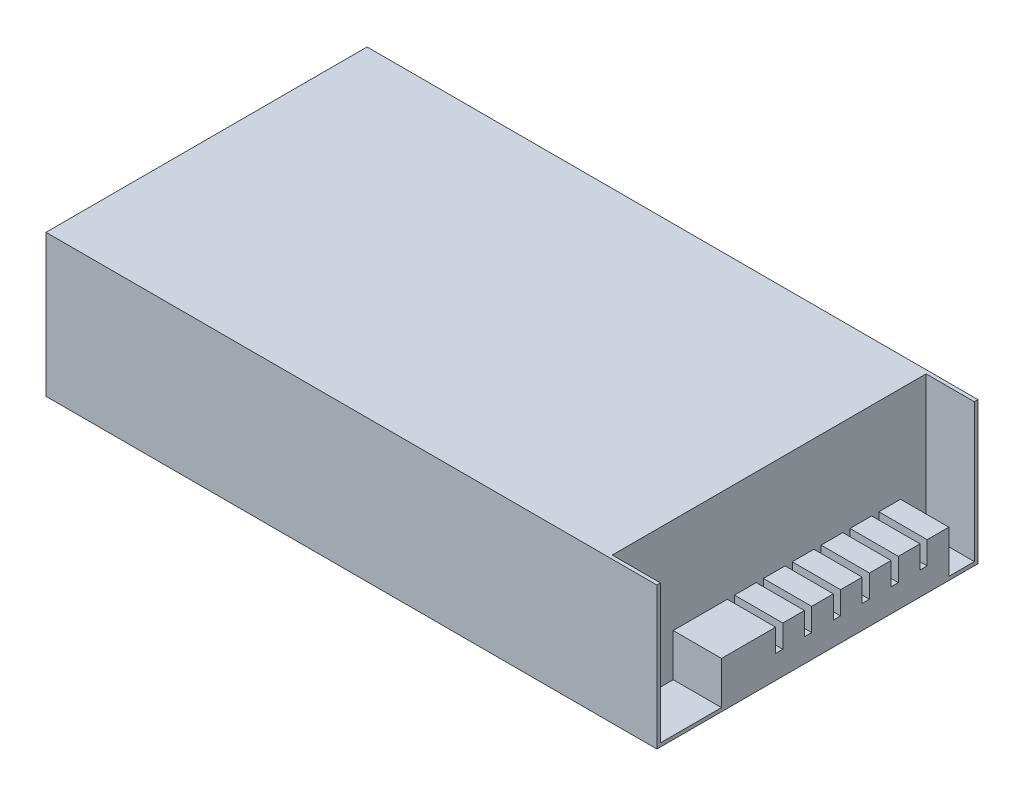
from build123d import *

# Parameters (mm, degrees)
SKETCH1_W           = 215
SKETCH1_H           = 113
BOSS_EXTRUDE1_DEPTH = 50
SKETCH2_W           = 110.46
SKETCH2_H           = 48.73
CUT_EXTRUDE1_DEPTH  = 17
SKETCH4_W           = 17
SKETCH4_H           = 80
BOSS_EXTRUDE2_DEPTH = 15
SKETCH6_R           = 1.27
CUT_EXTRUDE4_DEPTH  = 10.16
SKETCH7_W           = 17
SKETCH7_H           = 2.54
CUT_EXTRUDE5_DEPTH  = 8


with BuildPart() as part:
    # Sketch1 → Boss-Extrude1 (new body)
    with BuildSketch(Plane(origin=(0, 0, 0), x_dir=(1, 0, 0), z_dir=(0, 1, 0))):
        with Locations((107.5, 56.5)):
            Rectangle(SKETCH1_W, SKETCH1_H)
    extrude(amount=BOSS_EXTRUDE1_DEPTH)

    # Sketch2 → Cut-Extrude1 (cut)
    with BuildSketch(Plane(origin=(215, 0, 0), x_dir=(0, 0, -1), z_dir=(1, 0, 0))):
        with Locations((56.5, 25.635)):
            Rectangle(SKETCH2_W, SKETCH2_H)
    extrude(amount=-CUT_EXTRUDE1_DEPTH, mode=Mode.SUBTRACT)

    # Sketch4 → Boss-Extrude2 (add)
    with BuildSketch(Plane(origin=(0, 1.27, 0), x_dir=(1, 0, 0), z_dir=(0, 1, 0))):
        with Locations((206.5, 62.73)):
            Rectangle(SKETCH4_W, SKETCH4_H)
    extrude(amount=BOSS_EXTRUDE2_DEPTH)

    # Sketch6 → Cut-Extrude4 (cut)
    with BuildSketch(Plane.XZ):
        with Locations((113.146, -65.278)):
            Circle(SKETCH6_R)
        with Locations((190.87, -65.278)):
            Circle(SKETCH6_R)
    extrude(amount=-CUT_EXTRUDE4_DEPTH, mode=Mode.SUBTRACT)

    # Sketch7 → Cut-Extrude5 (cut)
    with BuildSketch(Plane(origin=(0, 16.27, 0), x_dir=(1, 0, 0), z_dir=(0, 1, 0))):
        with Locations((206.5, 93.84)):
            Rectangle(SKETCH7_W, SKETCH7_H)
        with Locations((206.5, 83.68)):
            Rectangle(SKETCH7_W, SKETCH7_H)
        with Locations((206.5, 73.52)):
            Rectangle(SKETCH7_W, SKETCH7_H)
        with Locations((206.5, 63.36)):
            Rectangle(SKETCH7_W, SKETCH7_H)
        with Locations((206.5, 53.2)):
            Rectangle(SKETCH7_W, SKETCH7_H)
        with Locations((206.5, 43.04)):
            Rectangle(SKETCH7_W, SKETCH7_H)
    extrude(amount=-CUT_EXTRUDE5_DEPTH, mode=Mode.SUBTRACT)


solid = part.part
